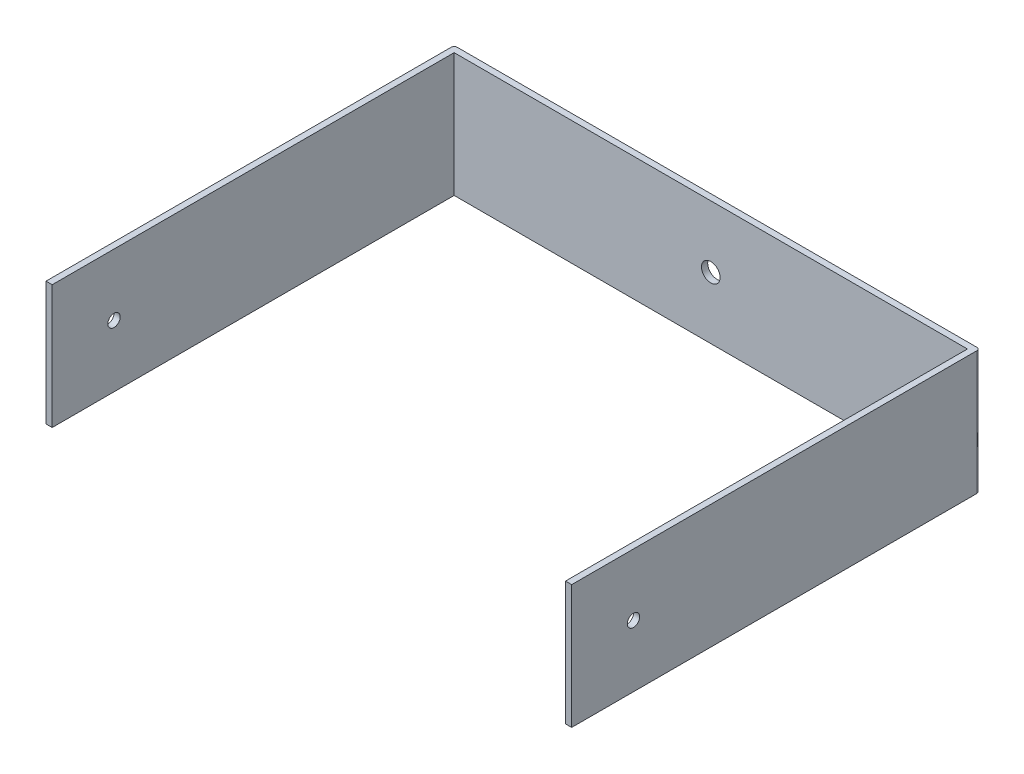
from build123d import *

# Parameters (mm, degrees)
ESQUISSE1_W             = 170
ESQUISSE1_H             = 40
BOSS_EXTRU_1_DEPTH      = 2
ESQUISSE2_W             = 2
ESQUISSE2_H             = 40
BOSS_EXTRU_2_DEPTH      = 130
ESQUISSE3_W             = 2
ESQUISSE3_H             = 40
BOSS_EXTRU_3_DEPTH      = 130
ESQUISSE4_R             = 2
ENL_V_MAT_EXTRU_1_DEPTH = 171
CONG_1_R                = 1
CONG_2_R                = 1
ESQUISSE5_R             = 3
ENL_V_MAT_EXTRU_2_DEPTH = 130


with BuildPart() as part:
    # Esquisse1 → Boss.-Extru.1 (new body)
    with BuildSketch(Plane.XY):
        with Locations((85, -20)):
            Rectangle(ESQUISSE1_W, ESQUISSE1_H)
    extrude(amount=BOSS_EXTRU_1_DEPTH)

    # Esquisse2 → Boss.-Extru.2 (add)
    with BuildSketch(Plane.XY.offset(2)):
        with Locations((1, -20)):
            Rectangle(ESQUISSE2_W, ESQUISSE2_H)
    extrude(amount=BOSS_EXTRU_2_DEPTH)

    # Esquisse3 → Boss.-Extru.3 (add)
    with BuildSketch(Plane.XY.offset(2)):
        with Locations((169, -20)):
            Rectangle(ESQUISSE3_W, ESQUISSE3_H)
    extrude(amount=BOSS_EXTRU_3_DEPTH)

    # Esquisse4 → Enlèv. mat.-Extru.1 (cut, through all)
    with BuildSketch(Plane.ZY):
        with Locations((112, -20)):
            Circle(ESQUISSE4_R)
    extrude(amount=-ENL_V_MAT_EXTRU_1_DEPTH, mode=Mode.SUBTRACT)

    # Congé1
    cong_1_edges = [part.edges().sort_by_distance(p)[0] for p in [
        (0, -20, 0),
    ]]
    fillet(cong_1_edges, radius=CONG_1_R)

    # Congé2
    cong_2_edges = [part.edges().sort_by_distance(p)[0] for p in [
        (170, -20, 0),
    ]]
    fillet(cong_2_edges, radius=CONG_2_R)

    # Esquisse5 → Enlèv. mat.-Extru.2 (cut)
    with BuildSketch(Plane.XY.offset(2)):
        with Locations((85, -20)):
            Circle(ESQUISSE5_R)
    extrude(amount=-ENL_V_MAT_EXTRU_2_DEPTH, mode=Mode.SUBTRACT)


solid = part.part
